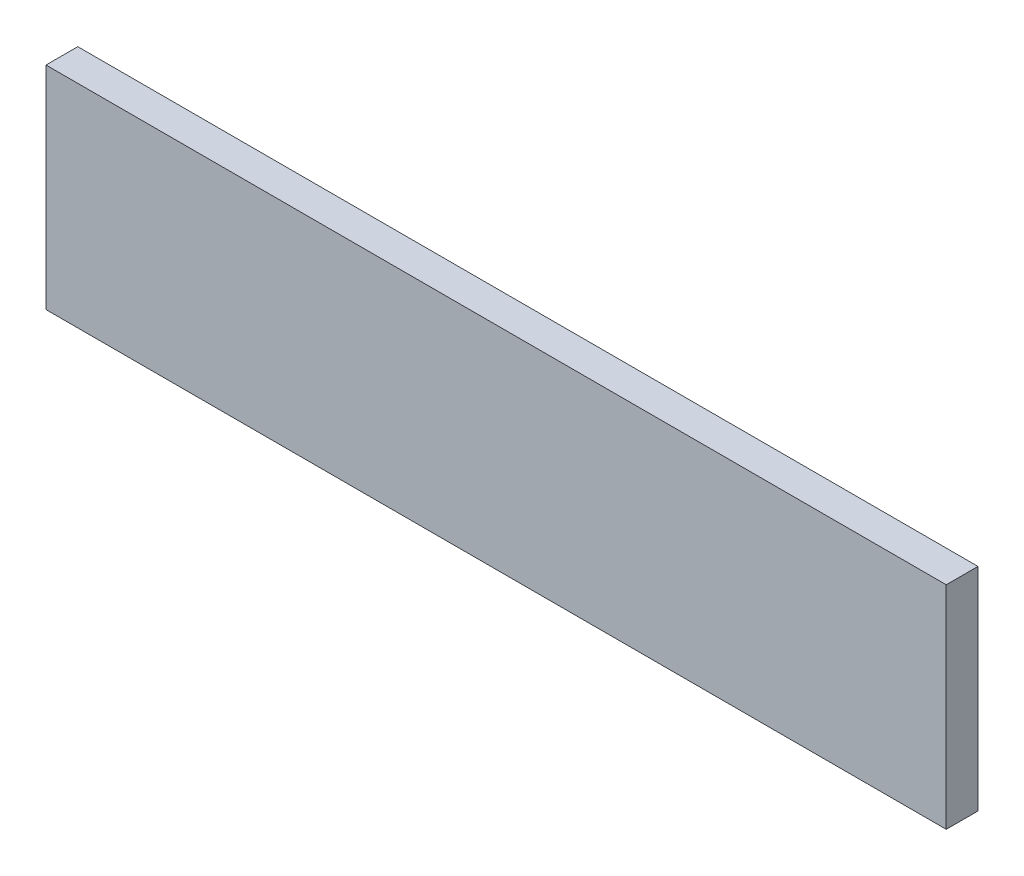
from build123d import *

# Parameters (mm, degrees)
SKETCH_1_W      = 170
SKETCH_1_H      = 40
EXTRUDE_1_DEPTH = 6


with BuildPart() as part:
    # Эскиз1 → Вытянуть1 (new body)
    with BuildSketch(Plane.XY):
        with Locations((85, 20)):
            Rectangle(SKETCH_1_W, SKETCH_1_H)
    extrude(amount=EXTRUDE_1_DEPTH)


solid = part.part
